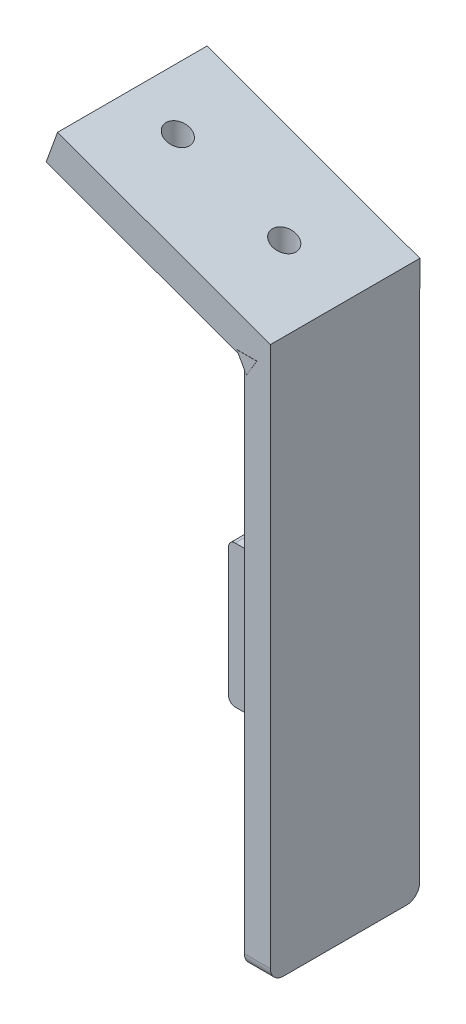
from build123d import *

# Parameters (mm, degrees)
ESQUISSE1_W             = 4
ESQUISSE1_H             = 85
BOSS_EXTRU_1_DEPTH      = 22.93
BOSS_EXTRU_5_DEPTH      = 22.95
CONG_1_R                = 2
ESQUISSE7_W             = 4
ESQUISSE7_H             = 21.820353027
BOSS_EXTRU_10_DEPTH     = 25.35
CONG_14_R               = 1
CONG_15_R               = 1
ESQUISSE9_R             = 1.8
ENL_V_MAT_EXTRU_1_DEPTH = 58
BOSS_EXTRU_11_DEPTH     = 1
BOSS_EXTRU_12_DEPTH     = 22.95


with BuildPart() as part:
    # Esquisse1 → Boss.-Extru.1 (new body)
    with BuildSketch(Plane.XY):
        with Locations((-2, -15.95097561)):
            Rectangle(ESQUISSE1_W, ESQUISSE1_H)
    extrude(amount=BOSS_EXTRU_1_DEPTH)

    # Esquisse2 → Boss.-Extru.5 (add)
    with BuildSketch(Plane.XY.offset(22.93)):
        Polygon((-32.681935281, 38.444276031), (0, 26.54902439), (0, 22.54902439), (-4, 22.54902439), (-34.435421614, 33.626611925), align=None)
    extrude(amount=-BOSS_EXTRU_5_DEPTH)

    # Congé1
    cong_1_edges = [part.edges().sort_by_distance(p)[0] for p in [
        (-2, -58.45097561, 22.93),
        (-2, -58.45097561, 0),
    ]]
    fillet(cong_1_edges, radius=CONG_1_R)

    # Esquisse7 → Boss.-Extru.10 (add)
    with BuildSketch(Plane(origin=(0, 0, 0), x_dir=(0, 0, -1), z_dir=(1, 0, 0))):
        with Locations((-2, -32.381152124)):
            Rectangle(ESQUISSE7_W, ESQUISSE7_H)
    extrude(amount=-BOSS_EXTRU_10_DEPTH)

    # Congé14
    cong_14_edges = [part.edges().sort_by_distance(p)[0] for p in [
        (-25.35, -43.291328637, 2),
        (-25.35, -21.47097561, 2),
    ]]
    fillet(cong_14_edges, radius=CONG_14_R)

    # Congé15
    cong_15_edges = [part.edges().sort_by_distance(p)[0] for p in [
        (-14.175, -43.291328637, 0),
        (-25.35, -32.381152123, 0),
        (-14.175, -21.47097561, 0),
        (-25.057106781, -21.763868829, 0),
        (-25.057106781, -42.998435418, 0),
    ]]
    fillet(cong_15_edges, radius=CONG_15_R)

    # Esquisse9 → Enlèv. mat.-Extru.1 (cut)
    with BuildSketch(Plane(origin=(0, 0, 0), x_dir=(1, 0, 0), z_dir=(0, 1, 0))):
        with Locations((-25.73017615, -11.416199304)):
            Circle(ESQUISSE9_R)
        with Locations((-9.38920851, -11.416199304)):
            Circle(ESQUISSE9_R)
    extrude(amount=ENL_V_MAT_EXTRU_1_DEPTH, mode=Mode.SUBTRACT)

    # Esquisse10 → Boss.-Extru.11 (add)
    with BuildSketch(Plane.ZY.offset(4)):
        Polygon((7.751431337, 10.464501792), (12.751431337, 10.464501792), (12.751431337, 15.464501792), (10.751431337, 15.464501792), (10.751431337, 12.464501792), (7.751431337, 12.464501792), align=None)
    extrude(amount=BOSS_EXTRU_11_DEPTH)

    # Esquisse13 → Boss.-Extru.12 (add)
    with BuildSketch(Plane.XY):
        Polygon((-5.151966744, 23.320636857), (-3.656231692, 20.681104413), (-2.075100003, 23.320636857), align=None)
    extrude(amount=BOSS_EXTRU_12_DEPTH)


solid = part.part
